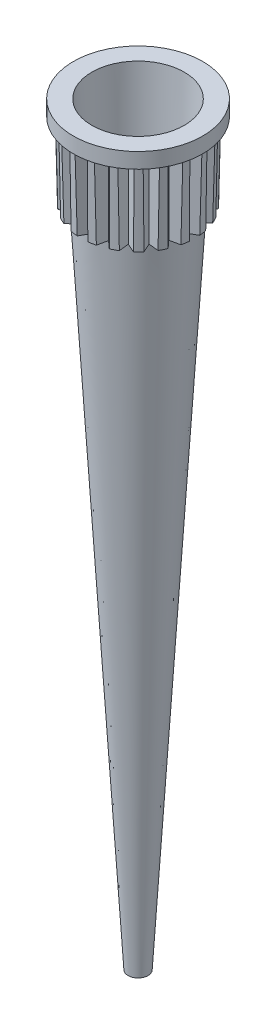
from build123d import *

# Parameters (mm, degrees)
IZIM2_R               = 3
KES_EKSTR_ZYON1_DEPTH = 49
KES_EKSTR_ZYON1_TAPER = 3
KES_EKSTR_ZYON4_DEPTH = 5
SCALE1_SCALE          = 0.880952381


with BuildPart() as part:
    # Çizim1 → Döndür1 (revolve)
    with BuildSketch(Plane.XY):
        Polygon((0, 0), (0, 49), (4.2, 49), (4.2, 48), (3.8, 48), (3.7, 43), (3.15, 43), (0.65, 0), align=None)
    revolve(axis=Axis((0, 0, 0), (0, 1, 0)))

    # Çizim2 → Kes-Ekstrüzyon1 (cut)
    with BuildSketch(Plane(origin=(0, 49, 0), x_dir=(1, 0, 0), z_dir=(0, 1, 0))):
        Circle(IZIM2_R)
    extrude(amount=-KES_EKSTR_ZYON1_DEPTH, taper=KES_EKSTR_ZYON1_TAPER, mode=Mode.SUBTRACT)

    # Çizim3 → Kes-Ekstrüzyon4 (cut)
    with BuildSketch(Plane.XZ.offset(-43)):
        Polygon((0.08224501, 3.1), (-0.41775499, 3.966025404), (0.58224501, 3.966025404), align=None)
        Polygon((0.815256969, 3.918905719), (1.766313485, 3.609888725), (1.02316866, 2.940758119), align=None)
        Polygon((1.973360244, 3.493070587), (2.782377238, 2.905285335), (1.868831781, 2.498548692), align=None)
        Polygon((2.943191617, 2.730203716), (3.53097687, 1.921186722), (2.536454974, 1.816658258), align=None)
        Polygon((3.629817237, 1.704979831), (3.938834232, 0.753923315), (2.960686631, 0.961835006), align=None)
        Polygon((3.966025404, 0.51775499), (3.966025404, -0.48224501), (3.1, 0.01775499), align=None)
        Polygon((3.918905719, -0.715256969), (3.609888725, -1.666313485), (2.940758119, -0.92316866), align=None)
        Polygon((3.493070587, -1.873360244), (2.905285335, -2.682377238), (2.498548692, -1.768831781), align=None)
        Polygon((2.730203716, -2.843191617), (1.921186722, -3.43097687), (1.816658258, -2.436454974), align=None)
        Polygon((1.704979831, -3.529817237), (0.753923315, -3.838834232), (0.961835006, -2.860686631), align=None)
        Polygon((0.51775499, -3.866025404), (-0.48224501, -3.866025404), (0.01775499, -3), align=None)
        Polygon((-0.715256969, -3.818905719), (-1.666313485, -3.509888725), (-0.92316866, -2.840758119), align=None)
        Polygon((-1.873360244, -3.393070587), (-2.682377238, -2.805285335), (-1.768831781, -2.398548692), align=None)
        Polygon((-2.843191617, -2.630203716), (-3.43097687, -1.821186722), (-2.436454974, -1.716658258), align=None)
        Polygon((-3.529817237, -1.604979831), (-3.838834232, -0.653923315), (-2.860686631, -0.861835006), align=None)
        Polygon((-3.866025404, -0.41775499), (-3.866025404, 0.58224501), (-3, 0.08224501), align=None)
        Polygon((-3.818905719, 0.815256969), (-3.509888725, 1.766313485), (-2.840758119, 1.02316866), align=None)
        Polygon((-3.393070587, 1.973360244), (-2.805285335, 2.782377238), (-2.398548692, 1.868831781), align=None)
        Polygon((-2.630203716, 2.943191617), (-1.821186722, 3.53097687), (-1.716658258, 2.536454974), align=None)
        Polygon((-1.604979831, 3.629817237), (-0.653923315, 3.938834232), (-0.861835006, 2.960686631), align=None)
    extrude(amount=-KES_EKSTR_ZYON4_DEPTH, mode=Mode.SUBTRACT)


with BuildPart() as part_1:
    # Scale1: scaled about (0.02225364, 34.813303108, 0.02225364)
    add(part.part.scale(SCALE1_SCALE).moved(Location((0.002649243, 4.144440846, 0.002649243))))


solid = part_1.part
